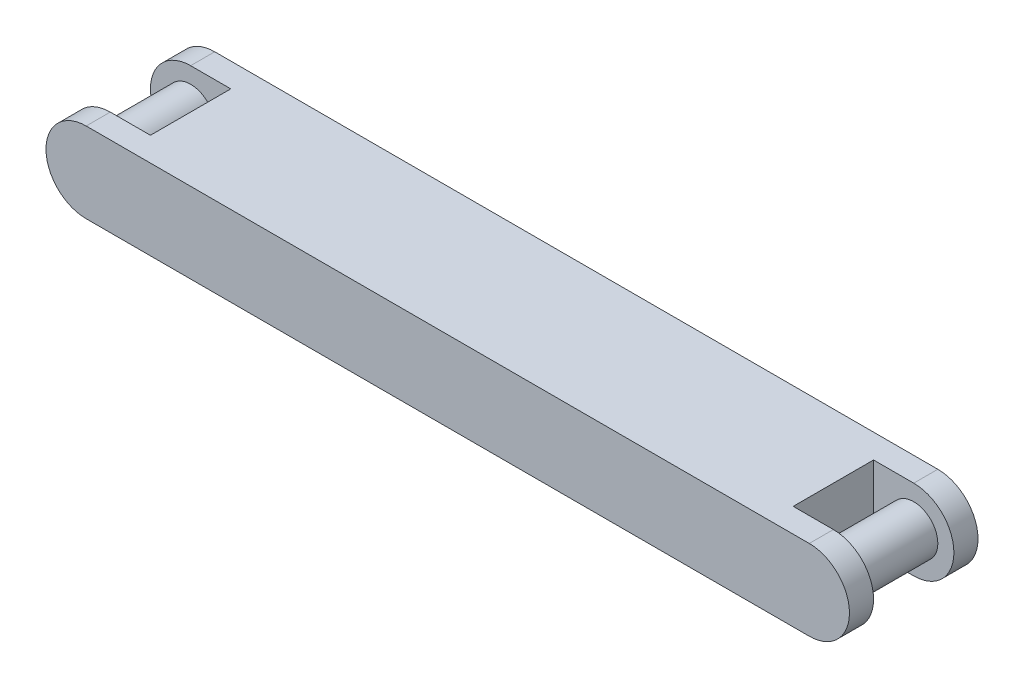
from build123d import *

# Parameters (mm, degrees)
SKETCH1_W                  = 254
SKETCH1_H                  = 31.75
BOSS_EXTRUDE1_DEPTH        = 25.4
BOSS_EXTRUDE1_DEPTH_BACK   = 25.4
SKETCH1_R                  = 9.525
BOSS_EXTRUDE1_2_DEPTH      = 25.4
BOSS_EXTRUDE1_2_DEPTH_BACK = 25.4
BOSS_EXTRUDE1_3_DEPTH      = 25.4
BOSS_EXTRUDE1_3_DEPTH_BACK = 25.4
BOSS_EXTRUDE2_START        = 25.4
SKETCH1_4_R                = 15.875
SKETCH1_4_R_2              = 9.525
BOSS_EXTRUDE2_DEPTH        = 9.525
BOSS_EXTRUDE3_START        = -25.4
SKETCH1_5_R                = 15.875
SKETCH1_5_R_2              = 9.525
BOSS_EXTRUDE3_DEPTH        = 9.525


with BuildPart() as part:
    # Sketch1 → Boss-Extrude1 (new body, two sides)
    with BuildSketch(Plane.XY) as boss_extrude1_sk:
        Rectangle(SKETCH1_W, SKETCH1_H)
    extrude(amount=BOSS_EXTRUDE1_DEPTH)
    extrude(boss_extrude1_sk.sketch, amount=-BOSS_EXTRUDE1_DEPTH_BACK)



with BuildPart() as body_2:
    # Sketch1 → Boss-Extrude1 2 (new body, two sides)
    with BuildSketch(Plane.XY) as boss_extrude1_2_sk:
        with Locations((-142.875, 0)):
            Circle(SKETCH1_R)
    extrude(amount=BOSS_EXTRUDE1_2_DEPTH)
    extrude(boss_extrude1_2_sk.sketch, amount=-BOSS_EXTRUDE1_2_DEPTH_BACK)


with BuildPart() as body_3:
    # Sketch1 → Boss-Extrude1 3 (new body, two sides)
    with BuildSketch(Plane.XY) as boss_extrude1_3_sk:
        with Locations((142.875, 0)):
            Circle(SKETCH1_R)
    extrude(amount=BOSS_EXTRUDE1_3_DEPTH)
    extrude(boss_extrude1_3_sk.sketch, amount=-BOSS_EXTRUDE1_3_DEPTH_BACK)


with BuildPart() as part_1:
    add(part.part)

    add(body_2.part)  # Boss-Extrude2 merges body 2

    add(body_3.part)  # Boss-Extrude2 merges body 3
    # Sketch1_4 → Boss-Extrude2 (add)
    with BuildSketch(Plane.XY.offset(BOSS_EXTRUDE2_START)):
        with BuildLine():
            Line((-127, 15.875), (-142.875, 15.875))
            ThreePointArc((-142.875, 15.875), (-131.649679849, 11.225320151), (-127, 0))
            Line((-127, 0), (-127, 15.875))
        make_face()
        with Locations((-142.875, 0)):
            Circle(SKETCH1_4_R)
        with Locations((-142.875, 0)):
            Circle(SKETCH1_4_R_2, mode=Mode.SUBTRACT)
        with BuildLine():
            Line((-127, -15.875), (-127, 0))
            ThreePointArc((-127, 0), (-131.649679849, -11.225320151), (-142.875, -15.875))
            Line((-142.875, -15.875), (-127, -15.875))
        make_face()
        with BuildLine():
            Line((142.875, 15.875), (127, 15.875))
            Line((127, 15.875), (127, 3.4e-08))
            ThreePointArc((127, 3.4e-08), (131.649679861, 11.225320163), (142.875, 15.875))
        make_face()
        with Locations((142.875, 0)):
            Circle(SKETCH1_4_R)
        with Locations((142.875, 0)):
            Circle(SKETCH1_4_R_2, mode=Mode.SUBTRACT)
        with BuildLine():
            ThreePointArc((142.875, -15.875), (131.649679837, -11.225320139), (127, 3.4e-08))
            Line((127, 3.4e-08), (127, -15.875))
            Line((127, -15.875), (142.875, -15.875))
        make_face()
    extrude(amount=-BOSS_EXTRUDE2_DEPTH)

    # Sketch1_5 → Boss-Extrude3 (add)
    with BuildSketch(Plane.XY.offset(BOSS_EXTRUDE3_START)):
        with Locations((-142.875, 0)):
            Circle(SKETCH1_5_R)
        with Locations((-142.875, 0)):
            Circle(SKETCH1_5_R_2, mode=Mode.SUBTRACT)
        with BuildLine():
            Line((-127, 15.875), (-142.875, 15.875))
            ThreePointArc((-142.875, 15.875), (-131.649679849, 11.225320151), (-127, 0))
            Line((-127, 0), (-127, 15.875))
        make_face()
        with BuildLine():
            Line((-127, -15.875), (-127, 0))
            ThreePointArc((-127, 0), (-131.649679849, -11.225320151), (-142.875, -15.875))
            Line((-142.875, -15.875), (-127, -15.875))
        make_face()
        with BuildLine():
            Line((142.875, 15.875), (127, 15.875))
            Line((127, 15.875), (127, 3.4e-08))
            ThreePointArc((127, 3.4e-08), (131.649679861, 11.225320163), (142.875, 15.875))
        make_face()
        with Locations((142.875, 0)):
            Circle(SKETCH1_5_R)
        with Locations((142.875, 0)):
            Circle(SKETCH1_5_R_2, mode=Mode.SUBTRACT)
        with BuildLine():
            ThreePointArc((142.875, -15.875), (131.649679837, -11.225320139), (127, 3.4e-08))
            Line((127, 3.4e-08), (127, -15.875))
            Line((127, -15.875), (142.875, -15.875))
        make_face()
    extrude(amount=BOSS_EXTRUDE3_DEPTH)


solid = part_1.part
